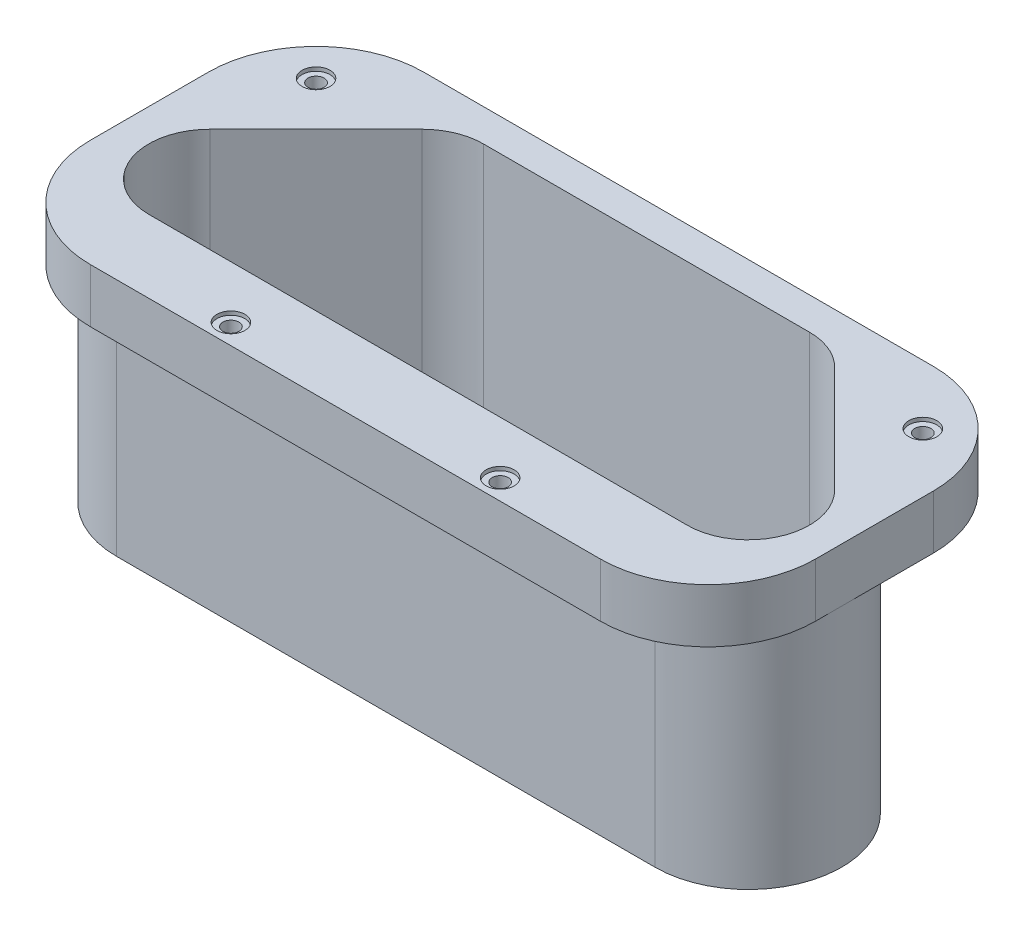
from build123d import *

# Parameters (mm, degrees)
SKETCH1_W             = 171.0436
SKETCH1_H             = 78.613
BOSS_EXTRUDE1_DEPTH   = 58.42
CUT_EXTRUDE1_DEPTH    = 45.72
BOSS_EXTRUDE2_DEPTH   = 7.62
FILLET1_R             = 25.4
F_6_CLEARANCE_HOLE2_D = 3.7973
SKETCH12_R            = 3.302
CUT_EXTRUDE2_DEPTH    = 0.889


with BuildPart() as part:
    # Sketch1 → Boss-Extrude1 (new body)
    with BuildSketch(Plane.XZ):
        with Locations((0, 0.485871825)):
            Rectangle(SKETCH1_W, SKETCH1_H)
        with BuildLine():
            Line((-73.683610441, -1.938038616), (-48.639210441, -26.982438616))
            ThreePointArc((-48.639210441, -26.982438616), (-43.966930256, -30.104356426), (-38.4556, -31.200628175))
            Line((-38.4556, -31.200628175), (38.4556, -31.200628175))
            ThreePointArc((38.4556, -31.200628175), (43.966930256, -30.104356426), (48.639210441, -26.982438616))
            Line((48.639210441, -26.982438616), (73.683610441, -1.938038616))
            ThreePointArc((73.683610441, -1.938038616), (76.805528251, 13.756902081), (63.5, 22.647371825))
            Line((63.5, 22.647371825), (-63.5, 22.647371825))
            ThreePointArc((-63.5, 22.647371825), (-76.805528251, 13.756902081), (-73.683610441, -1.938038616))
        make_face(mode=Mode.SUBTRACT)
    extrude(amount=BOSS_EXTRUDE1_DEPTH)

    # Sketch2 → Cut-Extrude1 (cut)
    with BuildSketch(Plane.XZ.offset(58.42)):
        with BuildLine():
            ThreePointArc((54.027364114, -32.370592289), (46.882978011, -37.144318464), (38.4556, -38.820628175))
            Line((38.4556, -38.820628175), (85.5218, -38.820628175))
            Line((85.5218, -38.820628175), (85.5218, 8.245571825))
            ThreePointArc((85.5218, 8.245571825), (83.845490289, -0.181806186), (79.071764114, -7.326192289))
            Line((79.071764114, -7.326192289), (54.027364114, -32.370592289))
        make_face()
        with BuildLine():
            Line((-85.5218, 8.245571825), (-85.5218, -38.820628175))
            Line((-85.5218, -38.820628175), (-38.4556, -38.820628175))
            ThreePointArc((-38.4556, -38.820628175), (-46.882978011, -37.144318464), (-54.027364114, -32.370592289))
            Line((-54.027364114, -32.370592289), (-79.071764114, -7.326192289))
            ThreePointArc((-79.071764114, -7.326192289), (-83.845490289, -0.181806186), (-85.5218, 8.245571825))
        make_face()
        with BuildLine():
            Line((-85.5218, 39.792371825), (-85.5218, 8.245571825))
            ThreePointArc((-85.5218, 8.245571825), (-79.071764114, 23.817335939), (-63.5, 30.267371825))
            Line((-63.5, 30.267371825), (63.5, 30.267371825))
            ThreePointArc((63.5, 30.267371825), (79.071764114, 23.817335939), (85.5218, 8.245571825))
            Line((85.5218, 8.245571825), (85.5218, 39.792371825))
            Line((85.5218, 39.792371825), (-85.5218, 39.792371825))
        make_face()
    extrude(amount=-CUT_EXTRUDE1_DEPTH, mode=Mode.SUBTRACT)

    # Sketch3 → Boss-Extrude2 (add)
    with BuildSketch(Plane.XZ.offset(58.42)):
        with BuildLine():
            Line((-79.071764114, -7.326192289), (-54.027364114, -32.370592289))
            ThreePointArc((-54.027364114, -32.370592289), (-46.882978011, -37.144318464), (-38.4556, -38.820628175))
            Line((-38.4556, -38.820628175), (38.4556, -38.820628175))
            ThreePointArc((38.4556, -38.820628175), (46.882978011, -37.144318464), (54.027364114, -32.370592289))
            Line((54.027364114, -32.370592289), (79.071764114, -7.326192289))
            ThreePointArc((79.071764114, -7.326192289), (83.845490289, 16.672949836), (63.5, 30.267371825))
            Line((63.5, 30.267371825), (-63.5, 30.267371825))
            ThreePointArc((-63.5, 30.267371825), (-83.845490289, 16.672949836), (-79.071764114, -7.326192289))
        make_face()
    extrude(amount=BOSS_EXTRUDE2_DEPTH)

    # Fillet1
    fillet1_edges = [part.edges().sort_by_distance(p)[0] for p in [
        (85.5218, -6.35, -38.820628175),
        (-85.5218, -6.35, -38.820628175),
        (-85.5218, -6.35, 39.792371825),
        (85.5218, -6.35, 39.792371825),
    ]]
    fillet(fillet1_edges, radius=FILLET1_R)

    # #6 Clearance Hole2 (through all)
    with Locations(Plane(origin=(0, -12.7, 0), x_dir=(-1, 0, 0), z_dir=(0, -1, 0))):
        with Locations((-31.75, -35.029871825), (-71.5518, 24.850628175)):
            f_6_clearance_hole2 = Hole(F_6_CLEARANCE_HOLE2_D / 2)

    # Mirror1: #6 Clearance Hole2 across plane
    add(f_6_clearance_hole2.mirror(Plane(origin=(0, 0, 0), x_dir=(0, 0, 1), z_dir=(1, 0, 0))), mode=Mode.SUBTRACT)

    # Sketch12 → Cut-Extrude2 (cut)
    with BuildSketch(Plane(origin=(0, 0, 0), x_dir=(1, 0, 0), z_dir=(0, 1, 0))):
        with Locations((-71.5518, 24.850628175)):
            Circle(SKETCH12_R)
        with Locations((-31.75, -35.029871825)):
            Circle(SKETCH12_R)
        with Locations((31.75, -35.029871825)):
            Circle(SKETCH12_R)
        with Locations((71.5518, 24.850628175)):
            Circle(SKETCH12_R)
    extrude(amount=-CUT_EXTRUDE2_DEPTH, mode=Mode.SUBTRACT)


solid = part.part
